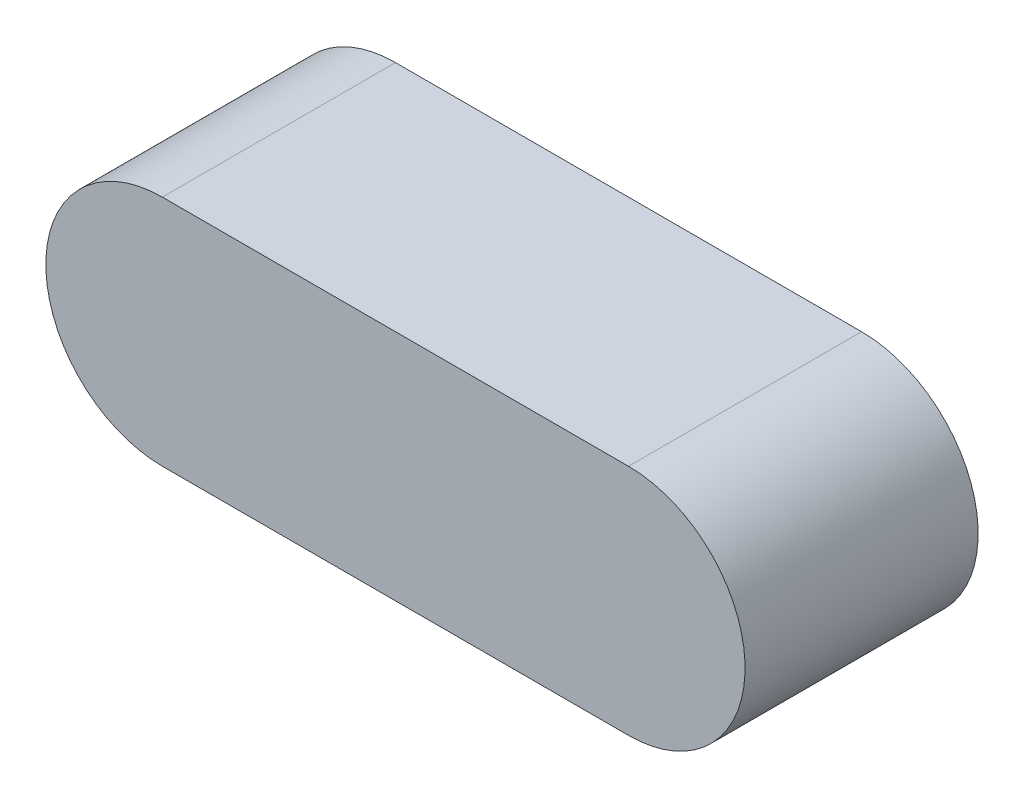
from build123d import *

# Parameters (mm, degrees)
BASE_EXTRUDE_DEPTH = 3


with BuildPart() as part:
    # Sketch1 → Base-Extrude (new body)
    with BuildSketch(Plane.XY):
        with BuildLine():
            Line((-3, 1.5), (3, 1.5))
            ThreePointArc((3, 1.5), (4.5, 0), (3, -1.5))
            Line((3, -1.5), (-3, -1.5))
            ThreePointArc((-3, -1.5), (-4.5, 0), (-3, 1.5))
        make_face()
    extrude(amount=BASE_EXTRUDE_DEPTH)


solid = part.part
